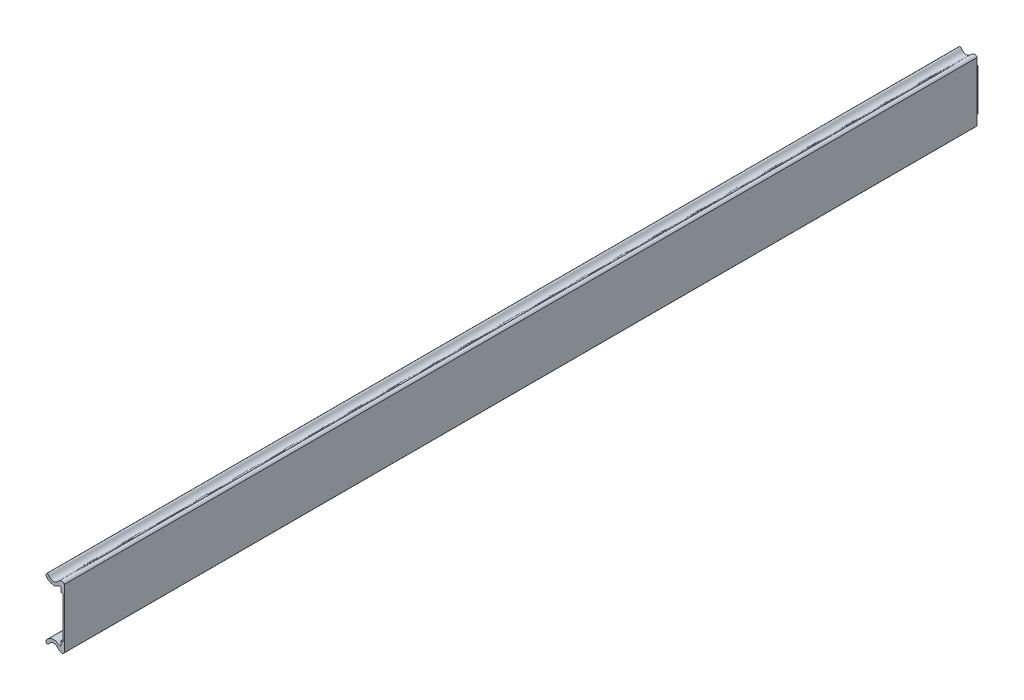
from build123d import *

# Parameters (mm, degrees)
BOSS_EXTRUDE1_DEPTH = 346.02
BOSS_EXTRUDE2_DEPTH = 0.8


with BuildPart() as part:
    # Sketch4 → Boss-Extrude1 (new body)
    with BuildSketch(Plane.XY):
        with BuildLine():
            Line((11.603676859, 3944.376448069), (12.395523288, 3944.376448069))
            Line((12.395523288, 3944.376448069), (12.395523288, 3928.522950851))
            Line((12.395523288, 3928.522950851), (11.603676859, 3928.522950851))
            Line((11.603676859, 3928.522950851), (11.603676859, 3927.018412498))
            add(Edge.make_bspline(
                [(11.603676859, 3927.018412498), (11.611475076, 3926.853580205), (11.509912091, 3926.710303062), (11.199525816, 3926.617205736), (10.996238337, 3926.681379138), (10.62802872, 3926.867568933), (10.494440178, 3926.944745468), (10.206867937, 3927.109476063), (10.052984165, 3927.196086051), (9.727196197, 3927.349764433), (9.555301512, 3927.416612176), (9.015787315, 3927.547230792), (8.624109396, 3927.546372701), (7.995114472, 3927.396361228), (7.77719542, 3927.320481464), (7.350075853, 3927.133760856), (7.14109885, 3927.023101437), (6.758952671, 3926.785124192), (6.587153097, 3926.658747814), (6.151733482, 3926.272126321), (5.965277254, 3926.000426915), (5.848366422, 3925.472208961), (5.971935047, 3924.972822865), (6.393772765, 3924.862987214), (6.684984599, 3924.977147644), (6.774571534, 3925.051021926), (6.952123758, 3925.245110676), (7.041404752, 3925.364099298), (7.243269014, 3925.612327871), (7.35719335, 3925.741273618), (7.623260922, 3925.977397387), (7.773616064, 3926.084967678), (8.105706742, 3926.251094101), (8.287703835, 3926.309267769), (8.874172111, 3926.370707087), (9.312842947, 3926.270070171), (9.843385768, 3926.000904178), (9.996193197, 3925.890950845), (10.270893706, 3925.655811021), (10.393252832, 3925.53071279), (10.628106454, 3925.291248187), (10.740753129, 3925.178352828), (11.033917915, 3924.92950643), (11.219953275, 3924.807769056), (11.521886929, 3924.692935024), (11.602141463, 3924.667305684), (12.026797646, 3924.575060898), (12.437982897, 3924.626683655), (12.864081602, 3925.224189599)],
                knots=[0, 0, 0, 0, 0.0625, 0.0625, 0.125, 0.125, 0.15625, 0.15625, 0.1875, 0.1875, 0.21875, 0.21875, 0.28125, 0.28125, 0.3125, 0.3125, 0.34375, 0.34375, 0.375, 0.375, 0.4375, 0.4375, 0.5, 0.5625, 0.5625, 0.59375, 0.59375, 0.625, 0.625, 0.65625, 0.65625, 0.6875, 0.6875, 0.71875, 0.71875, 0.78125, 0.78125, 0.8125, 0.8125, 0.84375, 0.84375, 0.875, 0.875, 0.921875, 0.921875, 0.9375, 0.9375, 1, 1, 1, 1], degree=3))
            Line((12.864081602, 3925.224189599), (12.864081602, 3928.33552367))
            add(Edge.make_bspline(
                [(12.864081602, 3928.33552367), (12.864081602, 3928.37970068), (12.864081602, 3928.431457267), (12.864081602, 3928.492452989), (12.864081602, 3928.510751706), (12.864081602, 3928.522950851)],
                knots=[0.5, 0.5, 0.5, 0.5, 1, 1, 1.333333333, 1.333333333, 1.333333333, 1.333333333], degree=3))
            Line((12.864081602, 3928.522950851), (12.864081602, 3944.376448069))
            add(Edge.make_bspline(
                [(12.864081602, 3944.376448069), (12.864081602, 3944.388647192), (12.864081602, 3944.406945877), (12.864081602, 3944.467941494), (12.864081602, 3944.519698002), (12.864081602, 3944.56387498)],
                knots=[0.5, 0.5, 0.5, 0.5, 1, 1, 1.75, 1.75, 1.75, 1.75], degree=3))
            Line((12.864081602, 3944.56387498), (12.864081602, 3947.67520932))
            add(Edge.make_bspline(
                [(12.864081602, 3947.67520932), (12.437982897, 3948.272715265), (12.026797646, 3948.324338021), (11.602141463, 3948.232093236), (11.521886929, 3948.206463895), (11.219953275, 3948.091629864), (11.033917915, 3947.969892489), (10.740753129, 3947.721046091), (10.628106454, 3947.608150732), (10.393252832, 3947.368686129), (10.270893706, 3947.243587899), (9.996193197, 3947.008448075), (9.843385768, 3946.898494742), (9.312842947, 3946.629328748), (8.874172111, 3946.528691833), (8.287703835, 3946.59013115), (8.105706742, 3946.648304818), (7.773616064, 3946.814431241), (7.623260922, 3946.922001533), (7.35719335, 3947.158125301), (7.243269014, 3947.287071049), (7.041404752, 3947.535299621), (6.952123758, 3947.654288244), (6.774571534, 3947.848376993), (6.684984599, 3947.922251276), (6.393772765, 3948.036411706), (5.971935047, 3947.926576054), (5.848366422, 3947.427189958), (5.965277254, 3946.898972004), (6.151733482, 3946.627272599), (6.587153097, 3946.240651105), (6.758952671, 3946.114274727), (7.14109885, 3945.876297482), (7.350075853, 3945.765638063), (7.77719542, 3945.578917456), (7.995114472, 3945.503037692), (8.624109396, 3945.353026218), (9.015787315, 3945.352168127), (9.555301512, 3945.482786744), (9.727196197, 3945.549634486), (10.052984165, 3945.703312869), (10.206867937, 3945.789922857), (10.494440178, 3945.954653452), (10.62802872, 3946.031829987), (10.996238337, 3946.218019782), (11.199525816, 3946.282193183), (11.509912091, 3946.189095858), (11.611475076, 3946.045818715), (11.603676859, 3945.880986421)],
                knots=[0, 0, 0, 0, 0.0625, 0.0625, 0.078125, 0.078125, 0.125, 0.125, 0.15625, 0.15625, 0.1875, 0.1875, 0.21875, 0.21875, 0.28125, 0.28125, 0.3125, 0.3125, 0.34375, 0.34375, 0.375, 0.375, 0.40625, 0.40625, 0.4375, 0.4375, 0.5, 0.5625, 0.5625, 0.625, 0.625, 0.65625, 0.65625, 0.6875, 0.6875, 0.71875, 0.71875, 0.78125, 0.78125, 0.8125, 0.8125, 0.84375, 0.84375, 0.875, 0.875, 0.9375, 0.9375, 1, 1, 1, 1], degree=3))
            Line((11.603676859, 3945.880986421), (11.603676859, 3944.376448069))
        make_face()
    extrude(amount=BOSS_EXTRUDE1_DEPTH)


with BuildPart() as body_2:
    # Sketch4_3 → Boss-Extrude2 (new body)
    with BuildSketch(Plane.XY):
        Polygon((12.395523288, 3944.376448069), (11.60834532, 3944.376448069), (11.603676859, 3944.376448069), (4.864629453, 3944.376448069), (4.864629453, 3928.522950851), (11.603676859, 3928.522950851), (11.60834532, 3928.522950851), (12.395523288, 3928.522950851), align=None)
    extrude(amount=-BOSS_EXTRUDE2_DEPTH)


solid = Compound([part.part, body_2.part])
